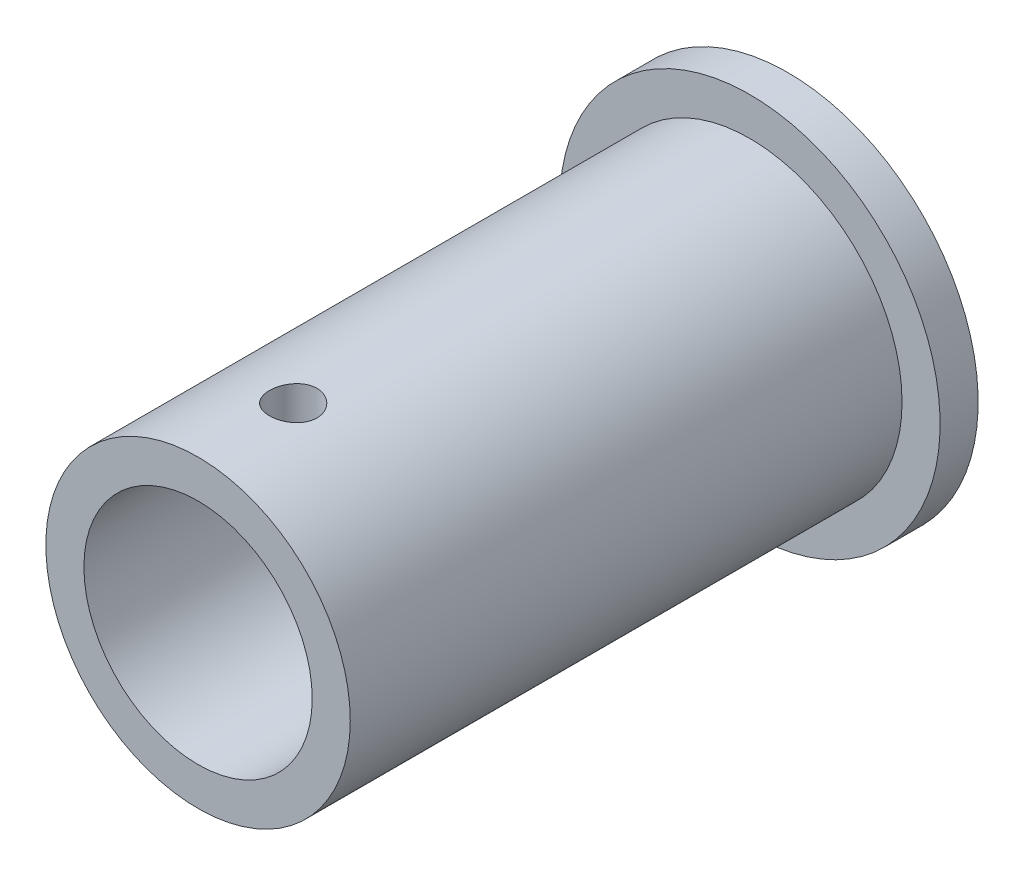
from build123d import *

# Parameters (mm, degrees)
SKETCH1_R           = 8
SKETCH1_R_2         = 6
BOSS_EXTRUDE1_DEPTH = 29
SKETCH2_R           = 10
SKETCH2_R_2         = 6
BOSS_EXTRUDE2_DEPTH = 2
SKETCH3_R           = 1.25
CUT_EXTRUDE1_DEPTH  = 11


with BuildPart() as part:
    # Sketch1 → Boss-Extrude1 (new body)
    with BuildSketch(Plane.XY):
        Circle(SKETCH1_R)
        Circle(SKETCH1_R_2, mode=Mode.SUBTRACT)
    extrude(amount=BOSS_EXTRUDE1_DEPTH)

    # Sketch3 → Cut-Extrude1 (cut, through all)
    with BuildSketch(Plane(origin=(0, 0, 0), x_dir=(1, 0, 0), z_dir=(0, 1, 0))):
        with Locations((0, -24)):
            Circle(SKETCH3_R)
    extrude(amount=CUT_EXTRUDE1_DEPTH, mode=Mode.SUBTRACT)


with BuildPart() as body_2:
    # Sketch2 → Boss-Extrude2 (new body)
    with BuildSketch(Plane(origin=(0, 0, 0), x_dir=(-1, 0, 0), z_dir=(0, 0, -1))):
        Circle(SKETCH2_R)
        Circle(SKETCH2_R_2, mode=Mode.SUBTRACT)
    extrude(amount=BOSS_EXTRUDE2_DEPTH)


solid = Compound([part.part, body_2.part])
